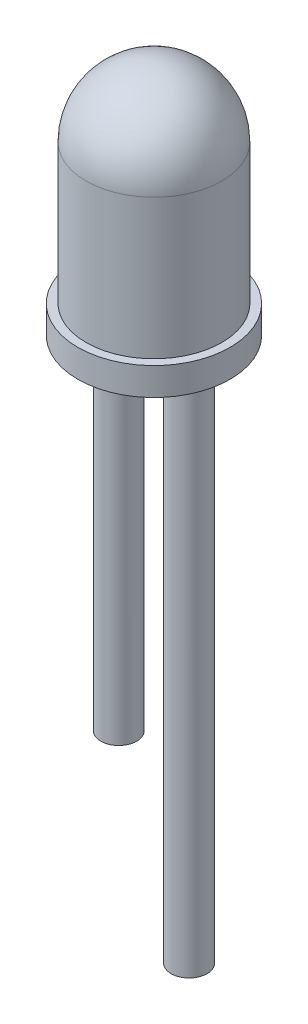
from build123d import *

# Parameters (mm, degrees)
CROQUIS1_R              = 2.75
SALIENTE_EXTRUIR1_DEPTH = 1
CROQUIS2_R              = 2.45
SALIENTE_EXTRUIR2_DEPTH = 5.05
C_PULA1_FACE_RADIUS     = 2.45
C_PULA1_HEIGHT          = 2.45
CROQUIS3_R              = 0.25
SALIENTE_EXTRUIR3_DEPTH = 16
CROQUIS5_R              = 0.25
SALIENTE_EXTRUIR5_DEPTH = 17
SKETCH2_R               = 0.25
CUT_EXTRUDE1_DEPTH      = 16
SKETCH3_R               = 0.25
CUT_EXTRUDE2_DEPTH      = 10
SKETCH4_R               = 0.65
BOSS_EXTRUDE1_DEPTH     = 13
SKETCH5_R               = 0.65
BOSS_EXTRUDE2_DEPTH     = 6


with BuildPart() as part:
    # Croquis1 → Saliente-Extruir1 (new body)
    with BuildSketch(Plane(origin=(0, 0, 0), x_dir=(1, 0, 0), z_dir=(0, 1, 0))):
        Circle(CROQUIS1_R)
    extrude(amount=SALIENTE_EXTRUIR1_DEPTH)

    # Croquis2 → Saliente-Extruir2 (add)
    with BuildSketch(Plane(origin=(0, 1, 0), x_dir=(1, 0, 0), z_dir=(0, 1, 0))):
        Circle(CROQUIS2_R)
    extrude(amount=SALIENTE_EXTRUIR2_DEPTH)

    # C_pula1: a dome of height H over a round flat face of radius A is a cap of a sphere of radius (A * A + H * H) / (2 * H)
    c_pula1_r = (C_PULA1_FACE_RADIUS * C_PULA1_FACE_RADIUS + C_PULA1_HEIGHT * C_PULA1_HEIGHT) / (2 * C_PULA1_HEIGHT)
    c_pula1_base = Plane((0, 6.05, 0), z_dir=(0, 1, 0))
    with Locations(c_pula1_base.offset(C_PULA1_HEIGHT - c_pula1_r)):
        c_pula1_ball = Sphere(c_pula1_r, mode=Mode.PRIVATE)
    add(split(c_pula1_ball, bisect_by=c_pula1_base, keep=Keep.TOP, mode=Mode.PRIVATE))

    # Croquis3 → Saliente-Extruir3 (add)
    with BuildSketch(Plane.XZ):
        with Locations((-1.205162028, 0)):
            Circle(CROQUIS3_R)
    extrude(amount=SALIENTE_EXTRUIR3_DEPTH)

    # Croquis5 → Saliente-Extruir5 (add)
    with BuildSketch(Plane.XZ):
        with Locations((1.205162028, 0)):
            Circle(CROQUIS5_R)
    extrude(amount=SALIENTE_EXTRUIR5_DEPTH)

    # Sketch2 → Cut-Extrude1 (cut)
    with BuildSketch(Plane.XZ.offset(16)):
        with Locations((-1.205162028, 0)):
            Circle(SKETCH2_R)
        with Locations((1.205162028, 0)):
            Circle(SKETCH2_R)
    extrude(amount=-CUT_EXTRUDE1_DEPTH, mode=Mode.SUBTRACT)

    # Sketch3 → Cut-Extrude2 (cut)
    with BuildSketch(Plane.XZ.offset(17)):
        with Locations((1.205162028, 0)):
            Circle(SKETCH3_R)
    extrude(amount=-CUT_EXTRUDE2_DEPTH, mode=Mode.SUBTRACT)

    # Sketch4 → Boss-Extrude1 (add)
    with BuildSketch(Plane.XZ):
        with Locations((1.27, 0)):
            Circle(SKETCH4_R)
        with Locations((-1.27, 0)):
            Circle(SKETCH4_R)
    extrude(amount=BOSS_EXTRUDE1_DEPTH)

    # Sketch5 → Boss-Extrude2 (add)
    with BuildSketch(Plane.XZ.offset(13)):
        with Locations((1.27, 0)):
            Circle(SKETCH5_R)
    extrude(amount=BOSS_EXTRUDE2_DEPTH)


solid = part.part
